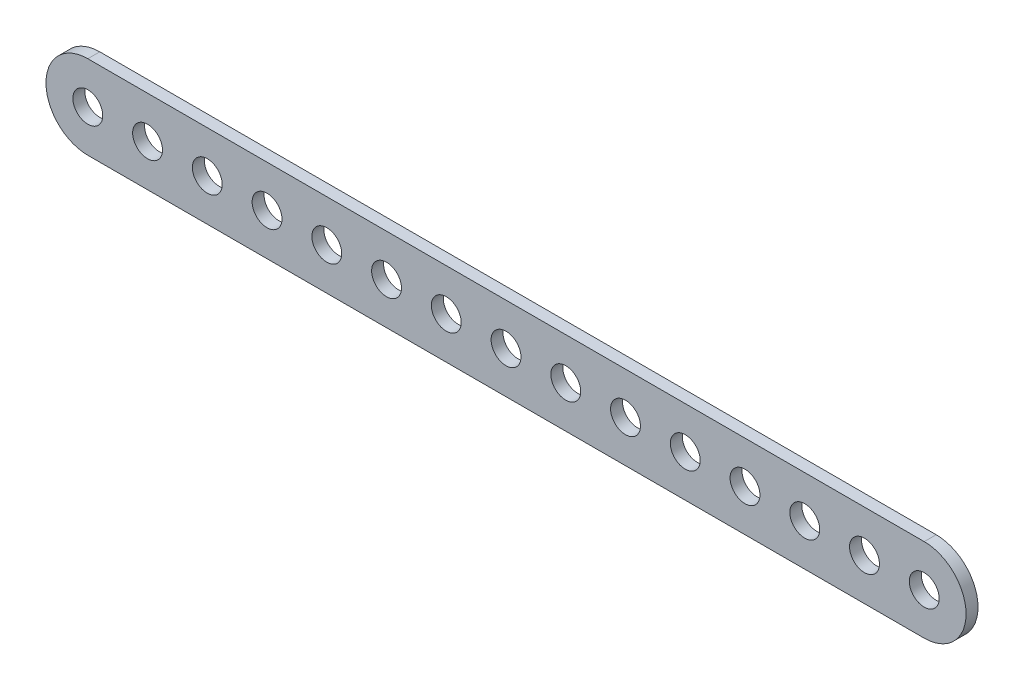
from build123d import *

# Parameters (mm, degrees)
SKETCH1_R           = 12.5
BOSS_EXTRUDE1_DEPTH = 10


with BuildPart() as part:
    # Sketch1 → Boss-Extrude1 (new body)
    with BuildSketch(Plane.XY):
        with BuildLine():
            Line((0, 35), (700, 35))
            ThreePointArc((700, 35), (735, 0), (700, -35))
            Line((700, -35), (0, -35))
            ThreePointArc((0, -35), (-35, 0), (0, 35))
        make_face()
        Circle(SKETCH1_R, mode=Mode.SUBTRACT)
        with Locations((50, 0)):
            Circle(SKETCH1_R, mode=Mode.SUBTRACT)
        with Locations((100, 0)):
            Circle(SKETCH1_R, mode=Mode.SUBTRACT)
        with Locations((150, 0)):
            Circle(SKETCH1_R, mode=Mode.SUBTRACT)
        with Locations((200, 0)):
            Circle(SKETCH1_R, mode=Mode.SUBTRACT)
        with Locations((250, 0)):
            Circle(SKETCH1_R, mode=Mode.SUBTRACT)
        with Locations((300, 0)):
            Circle(SKETCH1_R, mode=Mode.SUBTRACT)
        with Locations((350, 0)):
            Circle(SKETCH1_R, mode=Mode.SUBTRACT)
        with Locations((400, 0)):
            Circle(SKETCH1_R, mode=Mode.SUBTRACT)
        with Locations((450, 0)):
            Circle(SKETCH1_R, mode=Mode.SUBTRACT)
        with Locations((500, 0)):
            Circle(SKETCH1_R, mode=Mode.SUBTRACT)
        with Locations((550, 0)):
            Circle(SKETCH1_R, mode=Mode.SUBTRACT)
        with Locations((600, 0)):
            Circle(SKETCH1_R, mode=Mode.SUBTRACT)
        with Locations((650, 0)):
            Circle(SKETCH1_R, mode=Mode.SUBTRACT)
        with Locations((700, 0)):
            Circle(SKETCH1_R, mode=Mode.SUBTRACT)
    extrude(amount=BOSS_EXTRUDE1_DEPTH)


solid = part.part
